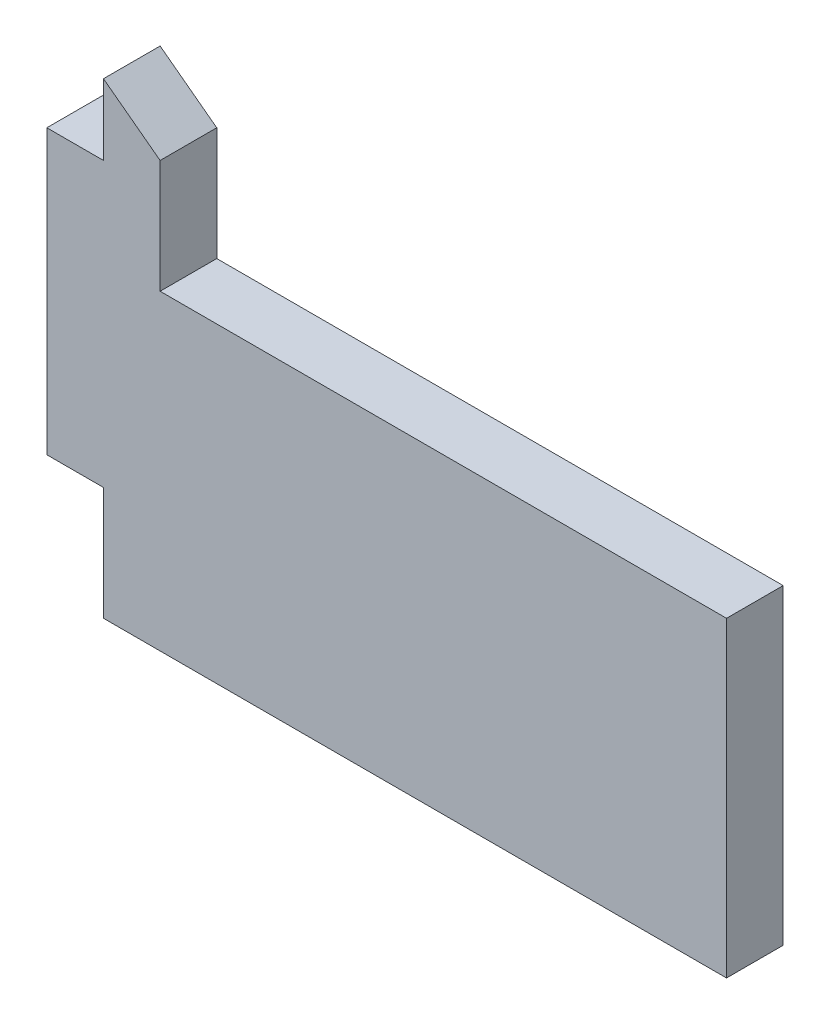
from build123d import *

# Parameters (mm, degrees)
EXTRUDE_1_DEPTH = 2


with BuildPart() as part:
    # ｽｹｯﾁ1 → ﾎﾞｽ - 押し出し1 (new body)
    with BuildSketch(Plane.XY):
        Polygon((0, 0), (0, 10), (2, 10), (2, 12.5), (4, 11), (4, 7), (24, 7), (24, -4), (2, -4), (2, 0), align=None)
    extrude(amount=EXTRUDE_1_DEPTH)


solid = part.part
